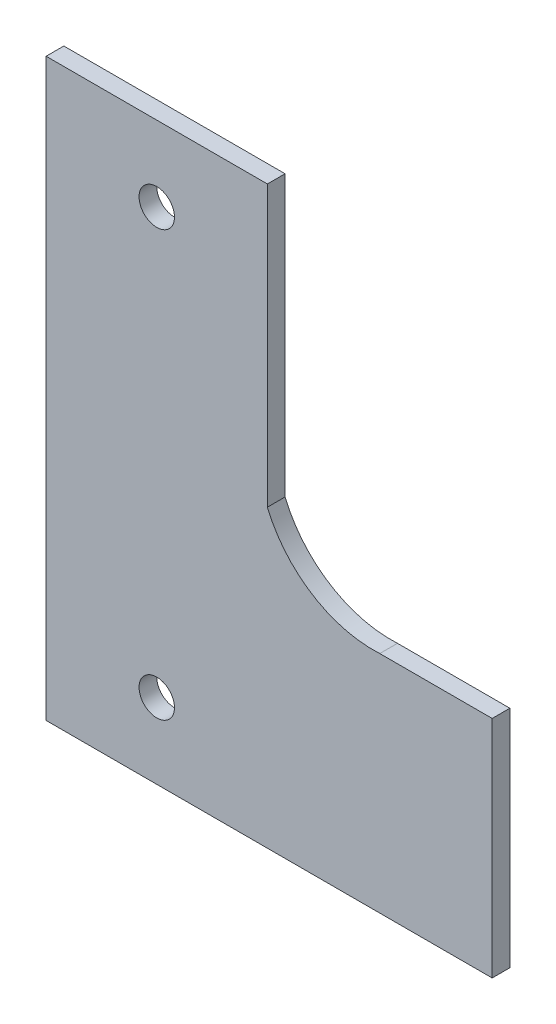
from build123d import *

# Parameters (mm, degrees)
SKETCH1_R           = 2
BOSS_EXTRUDE1_DEPTH = 2


with BuildPart() as part:
    # Sketch1 → Boss-Extrude1 (new body)
    with BuildSketch(Plane.XY):
        with BuildLine():
            Line((-15.236964255, 46.840062703), (-15.236964255, -18.159937297))
            Line((-15.236964255, -18.159937297), (35.163035745, -18.159937297))
            Line((35.163035745, -18.159937297), (35.163035745, 7.240062703))
            Line((35.163035745, 7.240062703), (22.463035745, 7.240062703))
            ThreePointArc((22.463035745, 7.240062703), (14.841940785, 9.199641421), (9.763035745, 15.210112346))
            Line((9.763035745, 15.210112346), (9.763035745, 46.840062703))
            Line((9.763035745, 46.840062703), (-15.236964255, 46.840062703))
        make_face()
        with Locations((-2.736964255, -9.659937297)):
            Circle(SKETCH1_R, mode=Mode.SUBTRACT)
        with Locations((-2.736964255, 38.340062703)):
            Circle(SKETCH1_R, mode=Mode.SUBTRACT)
    extrude(amount=BOSS_EXTRUDE1_DEPTH)


solid = part.part
